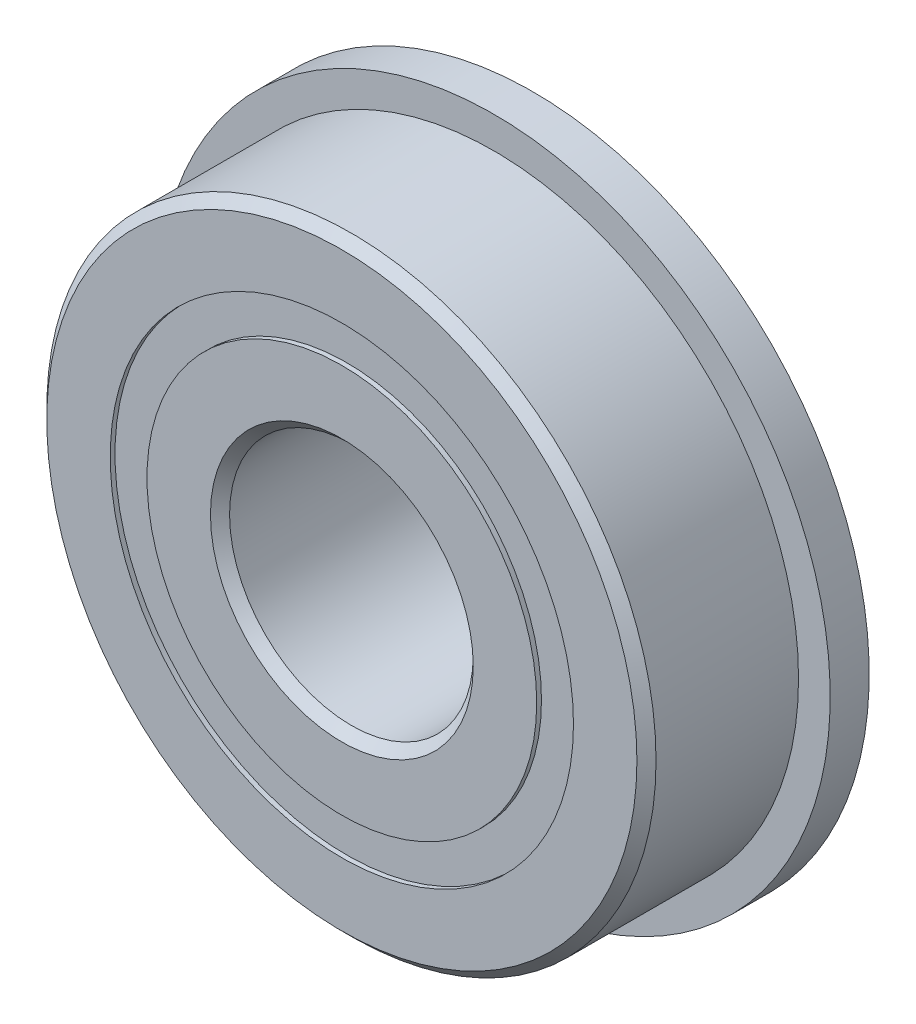
from build123d import *

# Parameters (mm, degrees)
CIRPATTERN1_COUNT = 14
SKETCH5_W         = 1.15919535
SKETCH5_H         = 0.957942858
SKETCH6_W         = 1.016
SKETCH6_H         = 2.727778571


with BuildPart() as part:
    # Sketch1 → Revolve1 (revolve)
    with BuildSketch(Plane(origin=(0, 0, 0), x_dir=(0, 0, -1), z_dir=(1, 0, 0))):
        with BuildLine():
            Line((2.24028, 7.9375), (-2.24028, 7.9375))
            Line((-2.24028, 7.9375), (-2.4892, 7.68858))
            Line((-2.4892, 7.68858), (-2.4892, 6.035221429))
            Line((-2.4892, 6.035221429), (-1.106311111, 6.035221429))
            ThreePointArc((-1.106311111, 6.035221429), (0, 6.76179465), (1.106311111, 6.035221429))
            Line((1.106311111, 6.035221429), (2.4892, 6.035221429))
            Line((2.4892, 6.035221429), (2.4892, 7.68858))
            Line((2.4892, 7.68858), (2.24028, 7.9375))
        make_face()
    revolve(axis=Axis((0, 0, 2.4892), (0, 0, -1)))

    # Sketch6 → Revolve6 (revolve)
    with BuildSketch(Plane(origin=(0, 0, 0), x_dir=(0, 0, -1), z_dir=(1, 0, 0))):
        with Locations((1.9812, 7.399110715)):
            Rectangle(SKETCH6_W, SKETCH6_H)
    revolve(axis=Axis((0, 0, -2.4892), (0, 0, 1)))


with BuildPart() as body_2:
    # Sketch3 → Revolve3 (revolve)
    with BuildSketch(Plane(origin=(0, 0, 0), x_dir=(0, 0, -1), z_dir=(1, 0, 0))):
        with BuildLine():
            Line((-2.4892, 5.077278571), (-1.106311111, 5.077278571))
            ThreePointArc((-1.106311111, 5.077278571), (0, 4.35070535), (1.106311111, 5.077278571))
            Line((1.106311111, 5.077278571), (2.4892, 5.077278571))
            Line((2.4892, 5.077278571), (2.4892, 3.42392))
            Line((2.4892, 3.42392), (2.24028, 3.175))
            Line((2.24028, 3.175), (-2.24028, 3.175))
            Line((-2.24028, 3.175), (-2.4892, 3.42392))
            Line((-2.4892, 3.42392), (-2.4892, 5.077278571))
        make_face()
    revolve(axis=Axis((0, 0, 2.4892), (0, 0, -1)))


with BuildPart() as body_3:
    # Sketch4 → Revolve4 (revolve)
    with BuildSketch(Plane(origin=(0, 0, 0), x_dir=(0, 0, -1), z_dir=(1, 0, 0))):
        with BuildLine():
            Line((-1.20554465, 5.55625), (1.20554465, 5.55625))
            ThreePointArc((1.20554465, 5.55625), (0, 6.76179465), (-1.20554465, 5.55625))
        make_face()
    revolve(axis=Axis((0, 5.55625, 1.20554465), (0, 0, -1)))


with BuildPart() as cirpattern1_1:
    # CirPattern1: pattern copy
    add(body_3.part.rotate(Axis((0, 0, 0), (0, 0, 1)), 1 * 360 / CIRPATTERN1_COUNT))


with BuildPart() as cirpattern1_2:
    # CirPattern1: pattern copy
    add(body_3.part.rotate(Axis((0, 0, 0), (0, 0, 1)), 2 * 360 / CIRPATTERN1_COUNT))


with BuildPart() as cirpattern1_3:
    # CirPattern1: pattern copy
    add(body_3.part.rotate(Axis((0, 0, 0), (0, 0, 1)), 3 * 360 / CIRPATTERN1_COUNT))


with BuildPart() as cirpattern1_4:
    # CirPattern1: pattern copy
    add(body_3.part.rotate(Axis((0, 0, 0), (0, 0, 1)), 4 * 360 / CIRPATTERN1_COUNT))


with BuildPart() as cirpattern1_5:
    # CirPattern1: pattern copy
    add(body_3.part.rotate(Axis((0, 0, 0), (0, 0, 1)), 5 * 360 / CIRPATTERN1_COUNT))


with BuildPart() as cirpattern1_6:
    # CirPattern1: pattern copy
    add(body_3.part.rotate(Axis((0, 0, 0), (0, 0, 1)), 6 * 360 / CIRPATTERN1_COUNT))


with BuildPart() as cirpattern1_7:
    # CirPattern1: pattern copy
    add(body_3.part.rotate(Axis((0, 0, 0), (0, 0, 1)), 7 * 360 / CIRPATTERN1_COUNT))


with BuildPart() as cirpattern1_8:
    # CirPattern1: pattern copy
    add(body_3.part.rotate(Axis((0, 0, 0), (0, 0, 1)), 8 * 360 / CIRPATTERN1_COUNT))


with BuildPart() as cirpattern1_9:
    # CirPattern1: pattern copy
    add(body_3.part.rotate(Axis((0, 0, 0), (0, 0, 1)), 9 * 360 / CIRPATTERN1_COUNT))


with BuildPart() as cirpattern1_10:
    # CirPattern1: pattern copy
    add(body_3.part.rotate(Axis((0, 0, 0), (0, 0, 1)), 10 * 360 / CIRPATTERN1_COUNT))


with BuildPart() as cirpattern1_11:
    # CirPattern1: pattern copy
    add(body_3.part.rotate(Axis((0, 0, 0), (0, 0, 1)), 11 * 360 / CIRPATTERN1_COUNT))


with BuildPart() as cirpattern1_12:
    # CirPattern1: pattern copy
    add(body_3.part.rotate(Axis((0, 0, 0), (0, 0, 1)), 12 * 360 / CIRPATTERN1_COUNT))


with BuildPart() as cirpattern1_13:
    # CirPattern1: pattern copy
    add(body_3.part.rotate(Axis((0, 0, 0), (0, 0, 1)), 13 * 360 / CIRPATTERN1_COUNT))


with BuildPart() as body_17:
    # Sketch5 → Revolve5 (revolve)
    with BuildSketch(Plane(origin=(0, 0, 0), x_dir=(0, 0, -1), z_dir=(1, 0, 0))):
        with Locations((-1.785142325, 5.55625)):
            Rectangle(SKETCH5_W, SKETCH5_H)
        with Locations((1.785142325, 5.55625)):
            Rectangle(SKETCH5_W, SKETCH5_H)
    revolve(axis=Axis((0, 0, 2.4892), (0, 0, -1)))


solid = Compound([part.part, body_2.part, body_3.part, cirpattern1_1.part, cirpattern1_2.part, cirpattern1_3.part, cirpattern1_4.part, cirpattern1_5.part, cirpattern1_6.part, cirpattern1_7.part, cirpattern1_8.part, cirpattern1_9.part, cirpattern1_10.part, cirpattern1_11.part, cirpattern1_12.part, cirpattern1_13.part, body_17.part])
